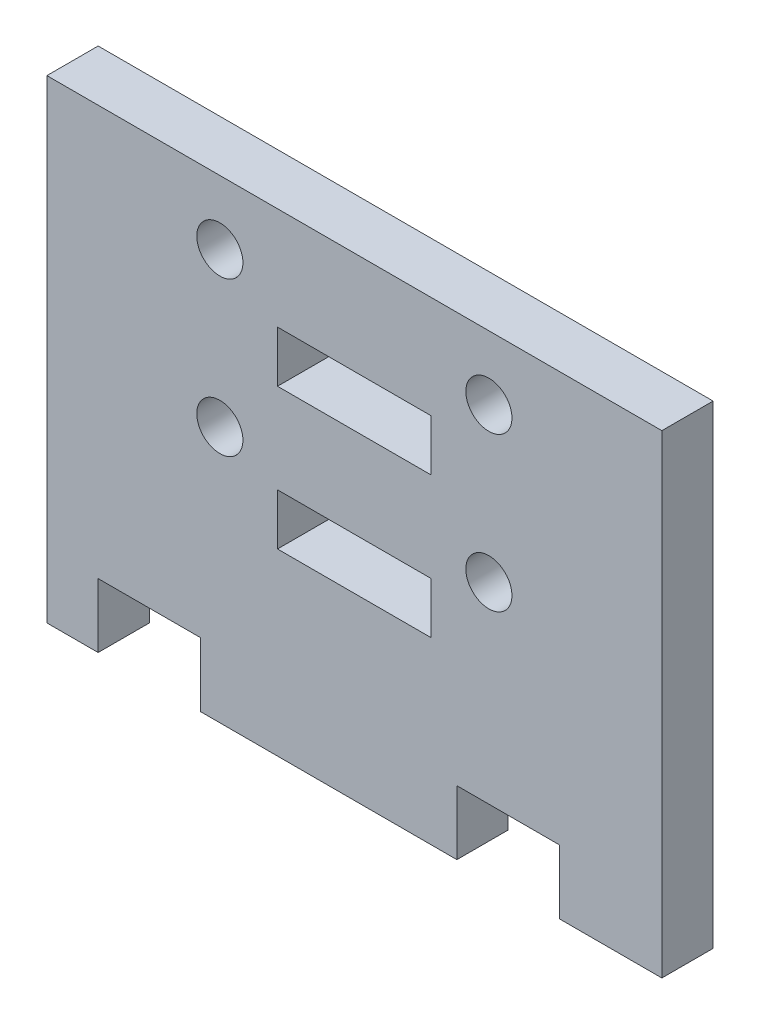
from build123d import *

# Parameters (mm, degrees)
SKETCH1_R           = 0.9
SKETCH1_W           = 6
SKETCH1_H           = 2
BOSS_EXTRUDE1_DEPTH = 2


with BuildPart() as part:
    # Sketch1 → Boss-Extrude1 (new body)
    with BuildSketch(Plane.XY):
        Polygon((59.240051945, 0), (49.240051945, 0), (49.240051945, 2.5), (45.240051945, 2.5), (45.240051945, 0), (43.240051945, 0), (43.240051945, 18.5), (67.240051945, 18.5), (67.240051945, 0), (63.240051945, 0), (63.240051945, 2.5), (59.240051945, 2.5), align=None)
        with Locations((60.490051945, 10)):
            Circle(SKETCH1_R, mode=Mode.SUBTRACT)
        with Locations((49.990051945, 16)):
            Circle(SKETCH1_R, mode=Mode.SUBTRACT)
        with Locations((49.990051945, 10)):
            Circle(SKETCH1_R, mode=Mode.SUBTRACT)
        with Locations((60.490051945, 16)):
            Circle(SKETCH1_R, mode=Mode.SUBTRACT)
        with Locations((55.240051945, 8)):
            Rectangle(SKETCH1_W, SKETCH1_H, mode=Mode.SUBTRACT)
        with Locations((55.240051945, 13.5)):
            Rectangle(SKETCH1_W, SKETCH1_H, mode=Mode.SUBTRACT)
    extrude(amount=BOSS_EXTRUDE1_DEPTH)


solid = part.part
